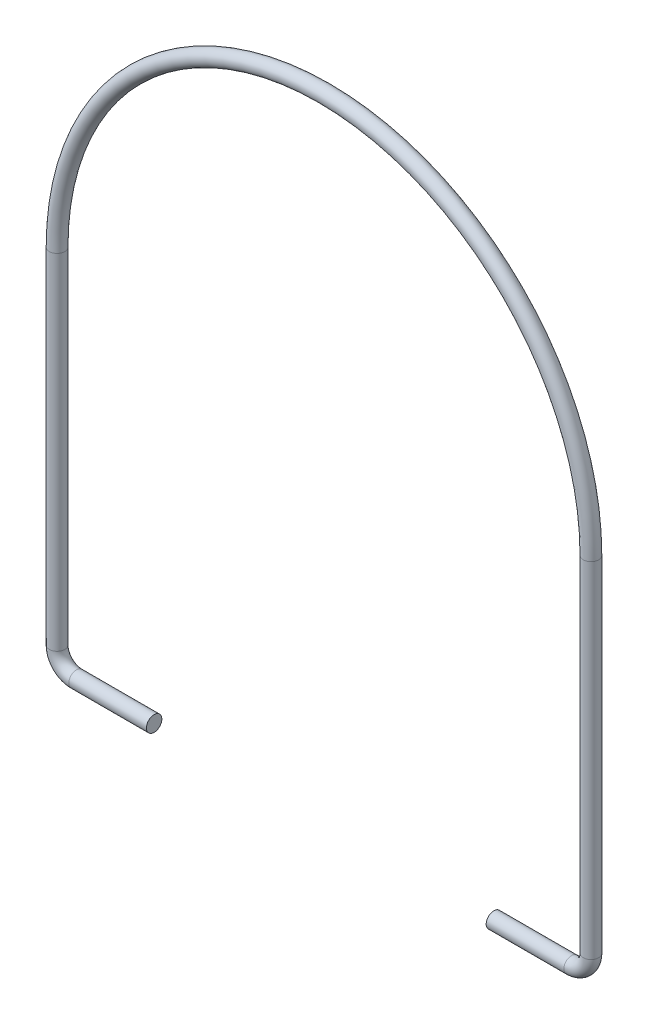
from build123d import *

# Parameters (mm, degrees)
SKETCH2_R = 1.5875


with BuildPart() as part:
    # Sweep1: sweep along a path in Sketch1
    with BuildLine(Plane.XY) as sweep1_path:
        Line((0, 0), (-16, 0))
        ThreePointArc((-16, 0), (-18.828427125, 1.171572875), (-20, 4))
        Line((-20, 4), (-20, 75))
        ThreePointArc((-20, 75), (35, 130), (90, 75))
        Line((90, 75), (90, 4))
        ThreePointArc((90, 4), (88.828427125, 1.171572875), (86, 0))
        Line((86, 0), (70, 0))
    # Sketch2 → Sweep1 (sweep)
    with BuildSketch(Plane(origin=(0, 0, 0), x_dir=(0, 0, -1), z_dir=(1, 0, 0))):
        Circle(SKETCH2_R)
    sweep(path=sweep1_path.line)


solid = part.part
